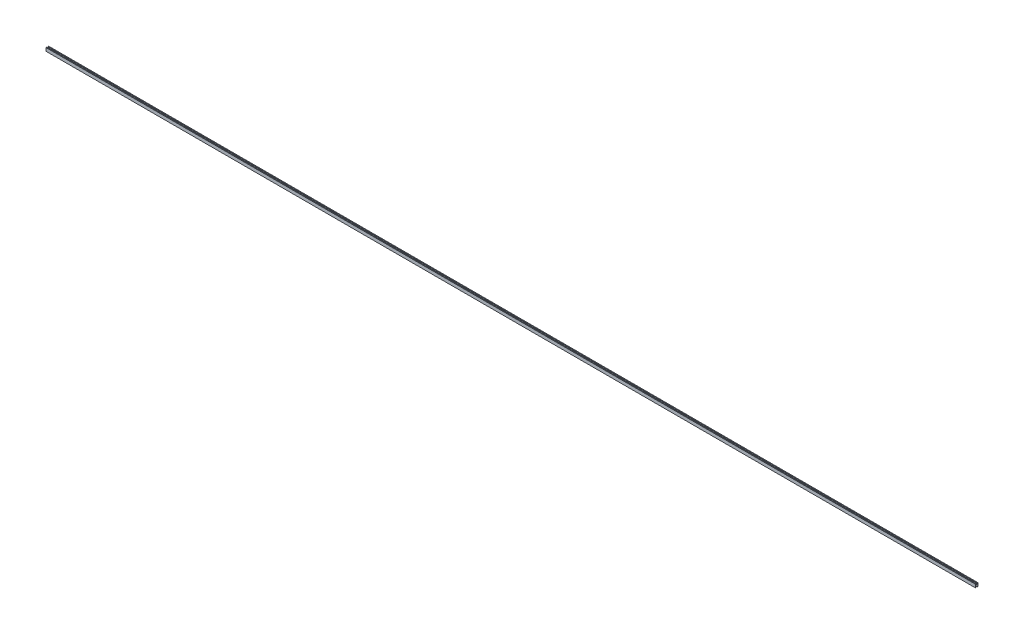
from build123d import *

# Parameters (mm, degrees)
BOSS_EXTRUDE1_DEPTH = 9144


with BuildPart() as part:
    # Sketch1 → Boss-Extrude1 (new body)
    with BuildSketch(Plane(origin=(0, 0, 0), x_dir=(0, 0, -1), z_dir=(1, 0, 0))):
        Polygon((5.08, -15.875), (12.7, -15.875), (12.7, 15.875), (5.08, 15.875), (5.08, 6.985), (-5.08, 6.985), (-5.08, 15.875), (-12.7, 15.875), (-12.7, -15.875), (-5.08, -15.875), (-5.08, -6.985), (5.08, -6.985), align=None)
    extrude(amount=BOSS_EXTRUDE1_DEPTH)


solid = part.part
